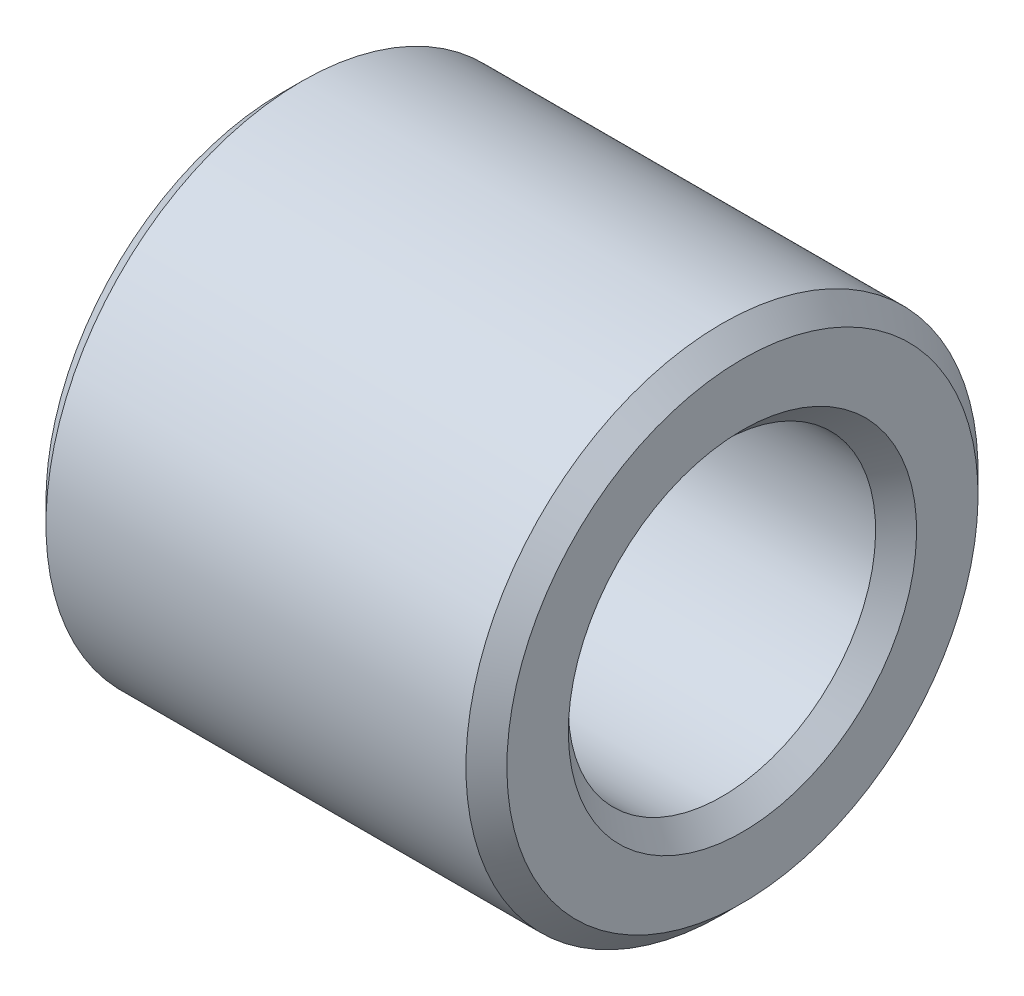
from build123d import *


with BuildPart() as part:
    # Sketch1 → Revolve1 (revolve)
    with BuildSketch(Plane.XY):
        Polygon((0, -1.7), (0, -2.3), (0.2, -2.5), (4.3, -2.5), (4.5, -2.3), (4.5, -1.7), (4.3, -1.5), (0.2, -1.5), align=None)
    revolve(axis=Axis((-3, 0, 0), (1, 0, 0)))


solid = part.part
